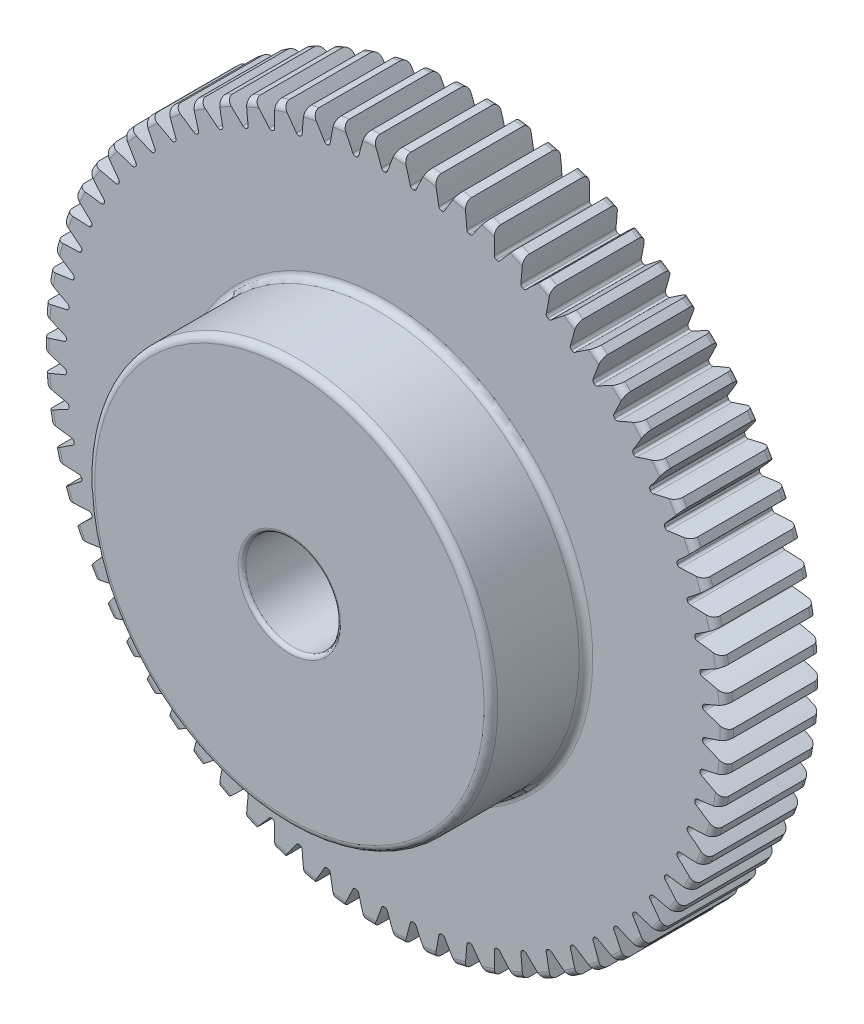
from build123d import *

# Parameters (mm, degrees)
FILLET2_R          = 0.9144
CUT_EXTRUDE2_DEPTH = 13.7
CIRPATTERN1_COUNT  = 70
FILLET3_R          = 0.508


with BuildPart() as part:
    # Sketch4 → Revolve1 (revolve)
    with BuildSketch(Plane(origin=(0, 0, 0), x_dir=(0, 0, -1), z_dir=(1, 0, 0))):
        Polygon((-25.4, 6.35), (-25.4, 26.924), (-12.7, 26.924), (-12.7, 45.72), (0, 45.72), (0, 6.35), align=None)
    revolve(axis=Axis((0, 0, 12.7), (0, 0, 1)))

    # Fillet2
    fillet2_edges = [part.edges().sort_by_distance(p)[0] for p in [
        (0, -45.72, 0),
        (0, -45.72, 12.7),
        (0, -26.924, 12.7),
        (0, -26.924, 25.4),
    ]]
    fillet(fillet2_edges, radius=FILLET2_R)

    # Sketch7 → Cut-Extrude2 (cut, through all)
    with BuildSketch(Plane.XY.offset(12.7)):
        with BuildLine():
            ThreePointArc((-0.035776995, 42.544984957), (0, 42.545), (0.035776995, 42.544984957))
            ThreePointArc((0.035776995, 42.544984957), (0.257128983, 42.615646356), (0.396284661, 42.80172546))
            ThreePointArc((0.396284661, 42.80172546), (0.927425025, 44.258110998), (1.50902682, 45.695089868))
            ThreePointArc((1.50902682, 45.695089868), (0, 45.72), (-1.50902682, 45.695089868))
            ThreePointArc((-1.50902682, 45.695089868), (-0.927425025, 44.258110998), (-0.396284661, 42.80172546))
            ThreePointArc((-0.396284661, 42.80172546), (-0.257128983, 42.615646356), (-0.035776995, 42.544984957))
        make_face()
    cut_extrude2 = extrude(amount=-CUT_EXTRUDE2_DEPTH, mode=Mode.SUBTRACT)

    # CirPattern1: Cut-Extrude2 ×70 about axis
    cirpattern1_axis = Axis((0, 0, 0), (0, 0, 1))
    for i in range(1, CIRPATTERN1_COUNT):
        add(cut_extrude2.rotate(cirpattern1_axis, i * 360 / CIRPATTERN1_COUNT), mode=Mode.SUBTRACT)

    # Fillet3
    fillet3_edges = [part.edges().sort_by_distance(p)[0] for p in [
        (0, -6.35, 0),
        (0, -6.35, 25.4),
    ]]
    fillet(fillet3_edges, radius=FILLET3_R)


solid = part.part
